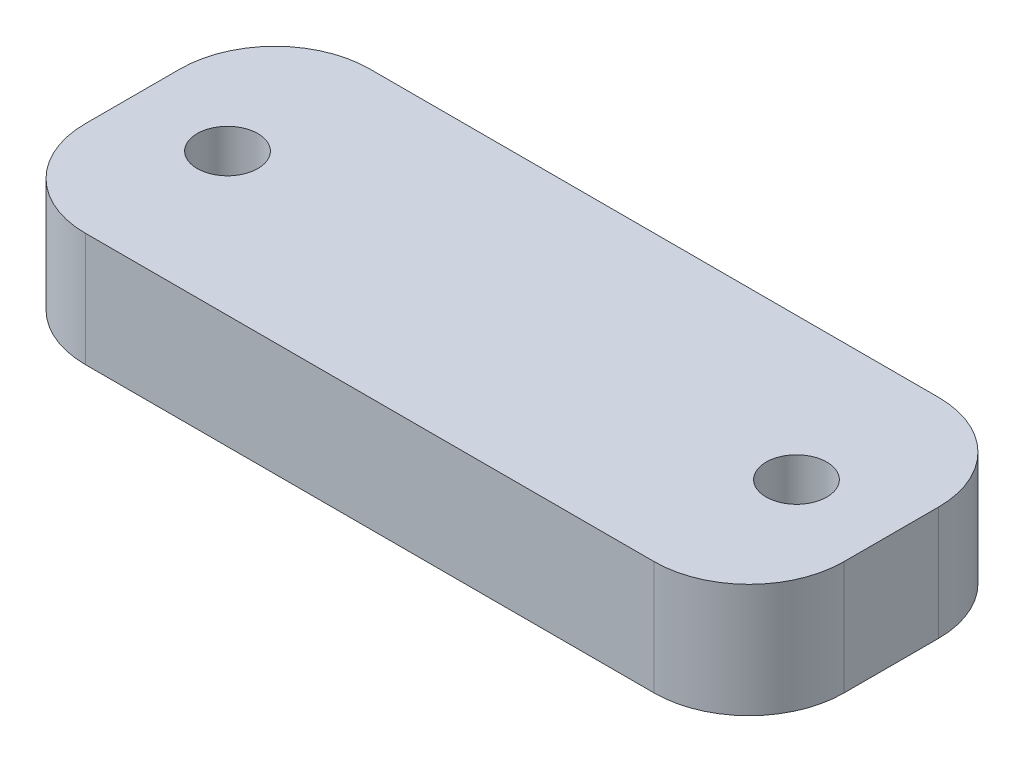
from build123d import *

# Parameters (mm, degrees)
SKETCH1_W            = 40
SKETCH1_H            = 15
BOSS_EXTRUDE1_DEPTH  = 6
M3_CLEARANCE_HOLE1_D = 3.2
FILLET1_R            = 5


with BuildPart() as part:
    # Sketch1 → Boss-Extrude1 (new body)
    with BuildSketch(Plane(origin=(0, 0, 0), x_dir=(1, 0, 0), z_dir=(0, 1, 0))):
        Rectangle(SKETCH1_W, SKETCH1_H)
    extrude(amount=BOSS_EXTRUDE1_DEPTH)

    # M3 Clearance Hole1 (through all)
    with Locations(Plane(origin=(0, 6, 0), x_dir=(1, 0, 0), z_dir=(0, 1, 0))):
        with Locations((-15, 0), (15, 0)):
            Hole(M3_CLEARANCE_HOLE1_D / 2)

    # Fillet1
    fillet1_edges = [part.edges().sort_by_distance(p)[0] for p in [
        (20, 3, 7.5),
        (-20, 3, 7.5),
        (-20, 3, -7.5),
        (20, 3, -7.5),
    ]]
    fillet(fillet1_edges, radius=FILLET1_R)


solid = part.part
